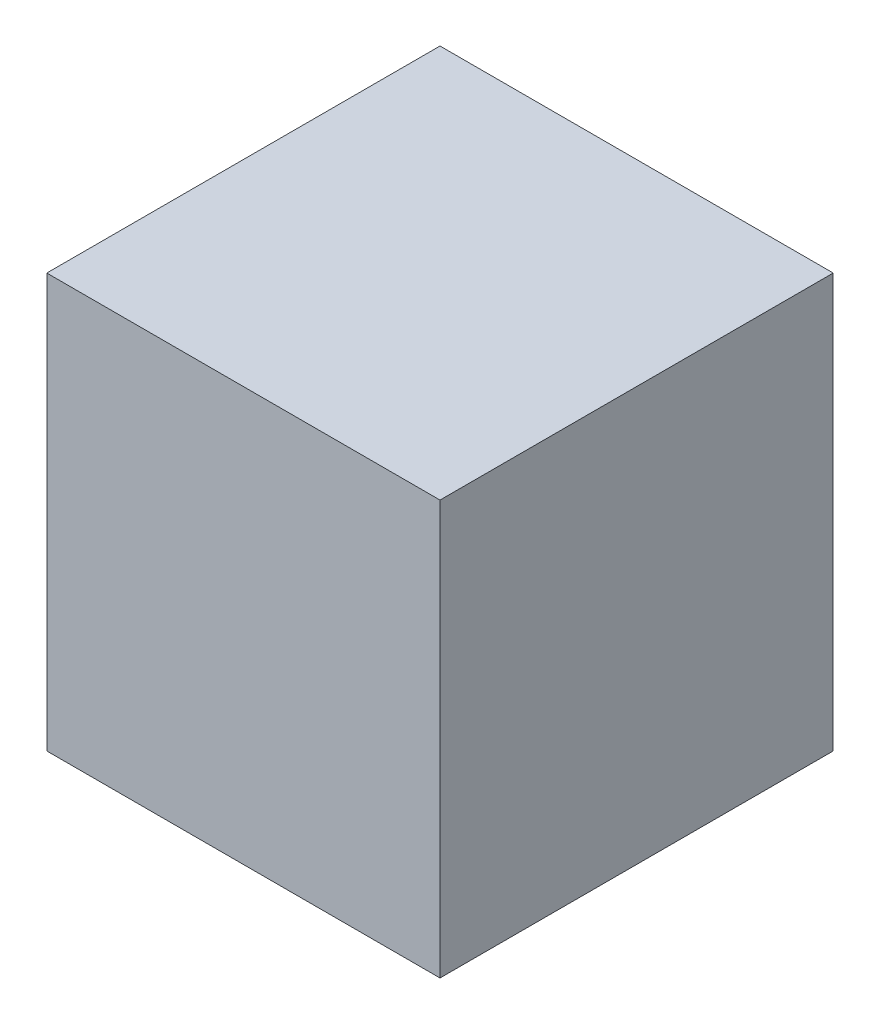
from build123d import *

# Parameters (mm, degrees)
SKETCH1_W           = 482.6
SKETCH1_H           = 482.6
BOSS_EXTRUDE1_DEPTH = 508


with BuildPart() as part:
    # Sketch1 → Boss-Extrude1 (new body)
    with BuildSketch(Plane(origin=(0, 0, 0), x_dir=(1, 0, 0), z_dir=(0, 1, 0))):
        Rectangle(SKETCH1_W, SKETCH1_H)
    extrude(amount=BOSS_EXTRUDE1_DEPTH)


solid = part.part
